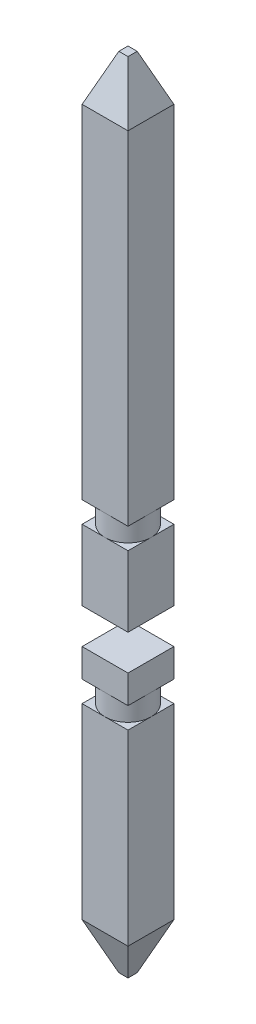
from build123d import *

# Parameters (mm, degrees)
SKETCH2_W             = 0.65
SKETCH2_H             = 0.65
BOSS_EXTRUDE1_DEPTH   = 11.3
SKETCH6_W             = 0.65
SKETCH6_H             = 0.5
CUT_EXTRUDE1_DEPTH    = 1.65
SKETCH7_W             = 0.65
SKETCH7_H             = 0.3
CUT_EXTRUDE2_DEPTH    = 1.65
SKETCH8_R             = 0.325
BOSS_EXTRUDE2_DEPTH   = 0.3
SKETCH9_W             = 0.65
SKETCH9_H             = 0.3
CUT_EXTRUDE3_DEPTH    = 1.65
SKETCH10_R            = 0.325
BOSS_EXTRUDE3_DEPTH   = 0.3
CHAMFER1_SIZE         = 0.65
CHAMFER1_SIZE2        = 0.26
CHAMFER1_PART_2_SIZE  = 0.65
CHAMFER1_PART_2_SIZE2 = 0.26
CHAMFER1_PART_3_SIZE  = 0.65
CHAMFER1_PART_3_SIZE2 = 0.26
CHAMFER1_PART_4_SIZE  = 0.65
CHAMFER1_PART_4_SIZE2 = 0.26
CHAMFER2_SIZE         = 0.26
CHAMFER2_SIZE2        = 0.65


with BuildPart() as part:
    # Sketch2 → Boss-Extrude1 (new body)
    with BuildSketch(Plane(origin=(0, 0, 0), x_dir=(1, 0, 0), z_dir=(0, 1, 0))):
        Rectangle(SKETCH2_W, SKETCH2_H)
    extrude(amount=BOSS_EXTRUDE1_DEPTH)

    # Sketch6 → Cut-Extrude1 (cut, through all)
    with BuildSketch(Plane.XY.offset(0.325)):
        with Locations((0, 4.25)):
            Rectangle(SKETCH6_W, SKETCH6_H)
    extrude(amount=-CUT_EXTRUDE1_DEPTH, mode=Mode.SUBTRACT)

    # Sketch7 → Cut-Extrude2 (cut, through all)
    with BuildSketch(Plane.XY.offset(0.325)):
        with Locations((0, 3.45)):
            Rectangle(SKETCH7_W, SKETCH7_H)
    extrude(amount=-CUT_EXTRUDE2_DEPTH, mode=Mode.SUBTRACT)

    # Sketch8 → Boss-Extrude2 (add)
    with BuildSketch(Plane(origin=(0, 3.3, 0), x_dir=(1, 0, 0), z_dir=(0, 1, 0))):
        Circle(SKETCH8_R)
    extrude(amount=BOSS_EXTRUDE2_DEPTH)

    # Sketch9 → Cut-Extrude3 (cut, through all)
    with BuildSketch(Plane.XY.offset(0.325)):
        with Locations((0, 5.65)):
            Rectangle(SKETCH9_W, SKETCH9_H)
    extrude(amount=-CUT_EXTRUDE3_DEPTH, mode=Mode.SUBTRACT)

    # Sketch10 → Boss-Extrude3 (add)
    with BuildSketch(Plane(origin=(0, 5.5, 0), x_dir=(1, 0, 0), z_dir=(0, 1, 0))):
        Circle(SKETCH10_R)
    extrude(amount=BOSS_EXTRUDE3_DEPTH)

    # Chamfer1
    chamfer1_edges = [part.edges().sort_by_distance(p)[0] for p in [
        (0.325, 11.3, 0),
    ]]
    chamfer1_side = [part.faces().sort_by_distance(p)[0] for p in [
        (0.325, 8.55, 0),
    ]]
    chamfer(chamfer1_edges, length=CHAMFER1_SIZE, length2=CHAMFER1_SIZE2, reference=chamfer1_side[0])

    # Chamfer1 part 2
    chamfer1_part_2_edges = [part.edges().sort_by_distance(p)[0] for p in [
        (0, 11.3, -0.325),
    ]]
    chamfer1_part_2_side = [part.faces().sort_by_distance(p)[0] for p in [
        (0, 8.55, -0.325),
    ]]
    chamfer(chamfer1_part_2_edges, length=CHAMFER1_PART_2_SIZE, length2=CHAMFER1_PART_2_SIZE2, reference=chamfer1_part_2_side[0])

    # Chamfer1 part 3
    chamfer1_part_3_edges = [part.edges().sort_by_distance(p)[0] for p in [
        (-0.325, 11.3, 0),
    ]]
    chamfer1_part_3_side = [part.faces().sort_by_distance(p)[0] for p in [
        (-0.325, 8.55, 0),
    ]]
    chamfer(chamfer1_part_3_edges, length=CHAMFER1_PART_3_SIZE, length2=CHAMFER1_PART_3_SIZE2, reference=chamfer1_part_3_side[0])

    # Chamfer1 part 4
    chamfer1_part_4_edges = [part.edges().sort_by_distance(p)[0] for p in [
        (0, 11.3, 0.325),
    ]]
    chamfer1_part_4_side = [part.faces().sort_by_distance(p)[0] for p in [
        (0, 8.55, 0.325),
    ]]
    chamfer(chamfer1_part_4_edges, length=CHAMFER1_PART_4_SIZE, length2=CHAMFER1_PART_4_SIZE2, reference=chamfer1_part_4_side[0])

    # Chamfer2
    chamfer2_edges = [part.edges().sort_by_distance(p)[0] for p in [
        (0, 0, 0.325),
        (-0.325, 0, 0),
        (0, 0, -0.325),
        (0.325, 0, 0),
    ]]
    chamfer2_side = [part.faces().sort_by_distance(p)[0] for p in [
        (0, 0, 0),
    ]]
    chamfer(chamfer2_edges, length=CHAMFER2_SIZE, length2=CHAMFER2_SIZE2, reference=chamfer2_side[0])


solid = part.part
